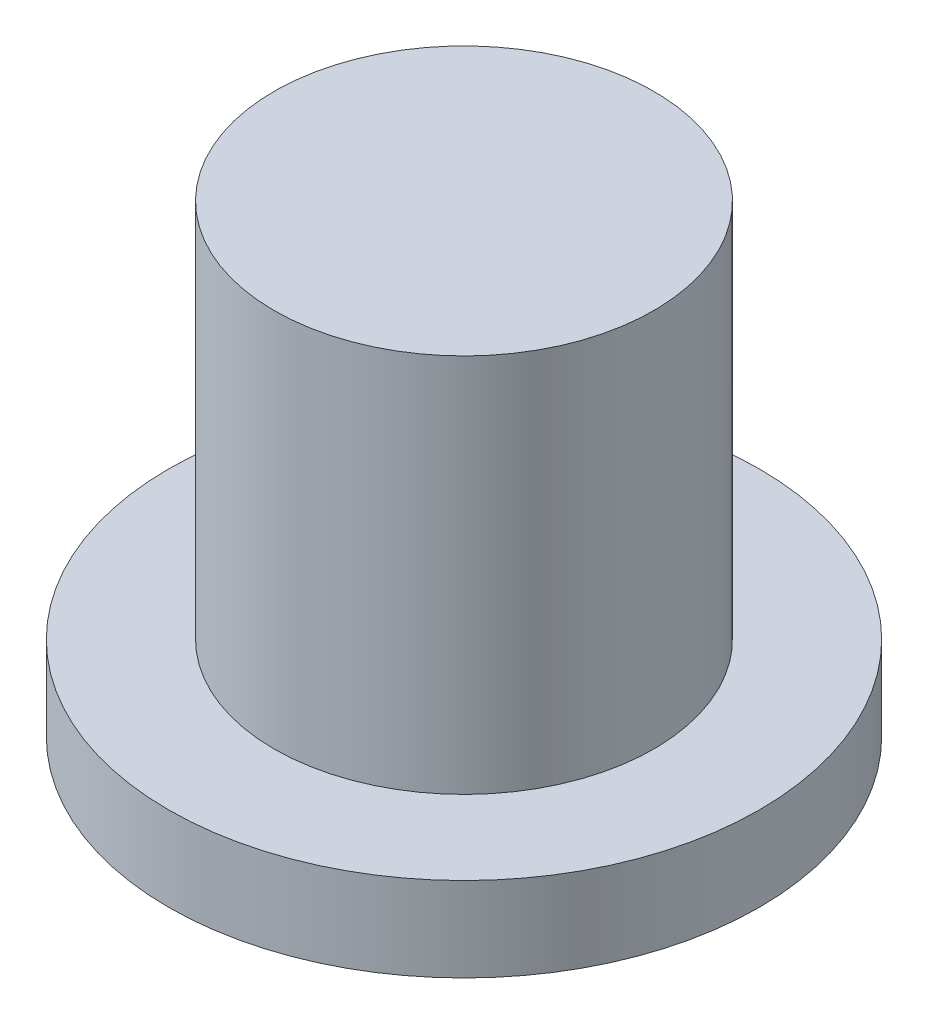
from build123d import *

# Parameters (mm, degrees)
SKETCH_1_R      = 3.5
EXTRUDE_1_DEPTH = 1
SKETCH_2_R      = 2.25
EXTRUDE_2_DEPTH = 4.5


with BuildPart() as part:
    # Эскиз1 → Бобышка-Вытянуть1 (new body)
    with BuildSketch(Plane(origin=(0, 0, 0), x_dir=(1, 0, 0), z_dir=(0, 1, 0))):
        Circle(SKETCH_1_R)
    extrude(amount=EXTRUDE_1_DEPTH)

    # Эскиз2 → Бобышка-Вытянуть2 (add)
    with BuildSketch(Plane(origin=(0, 1, 0), x_dir=(1, 0, 0), z_dir=(0, 1, 0))):
        Circle(SKETCH_2_R)
    extrude(amount=EXTRUDE_2_DEPTH)


solid = part.part
